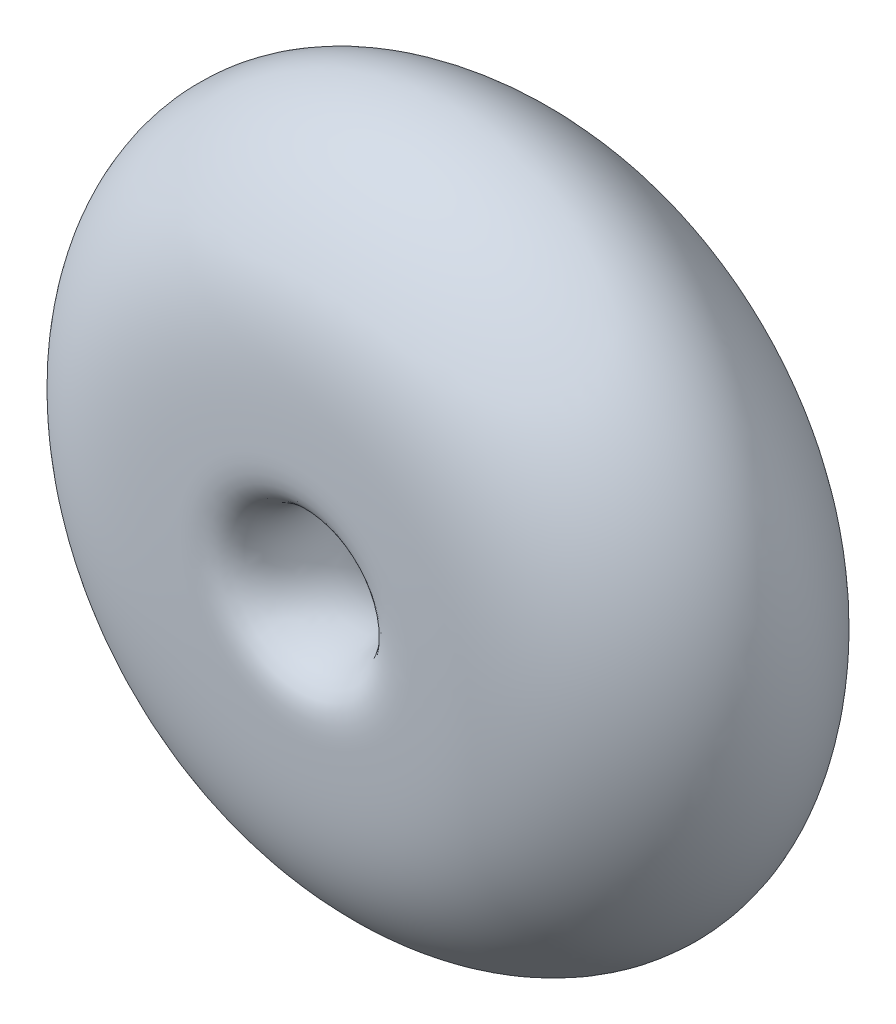
from build123d import *


with BuildPart() as part:
    # Sketch1 → Revolve1 (revolve)
    with BuildSketch(Plane(origin=(0, 0, 0), x_dir=(1, 0, 0), z_dir=(0, 1, 0))):
        with BuildLine():
            add(Edge.make_bspline(
                [(0, 1.043265494), (-7.446412552, 4.864849923), (-6.677761271, 36.698499158), (29.05451332, 30.565060222), (20.249825813, 75.586010084), (70.588129603, 37.622216416), (40.771776972, 0.947666876), (16.060067073, 0.20398496), (2.372669486, -0.174415731), (0, 1.043265494)],
                knots=[0, 0, 0, 0, 0.146650318, 0.27990839, 0.400677484, 0.586393354, 0.798212472, 0.953272434, 1, 1, 1, 1], degree=3))
        make_face()
    revolve(axis=Axis((-17.248656171, 0, -66.56033853), (0, 0, 1)))


solid = part.part
